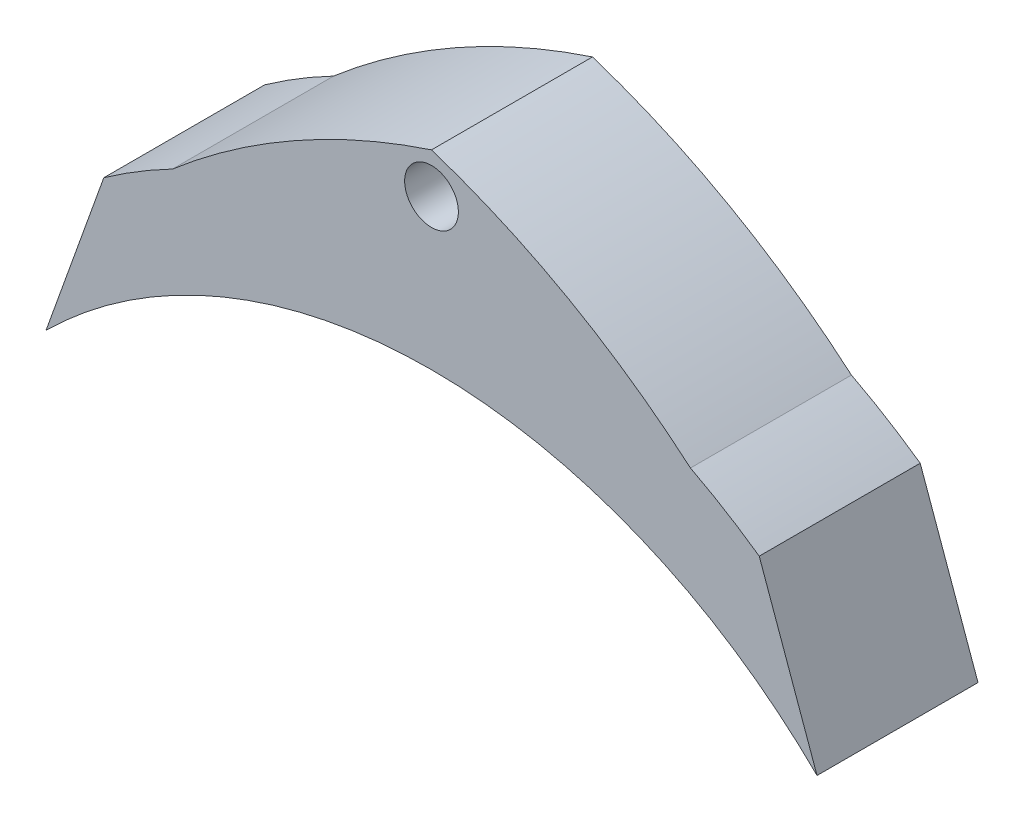
from build123d import *

# Parameters (mm, degrees)
BOSS_EXTRUDE1_DEPTH     = 30
SKETCH2_W               = 8.32
SKETCH2_H               = 8.5
SKETCH2_H_2             = 10.4
SKETCH2_W_2             = 4.158973904
SKETCH2_H_3             = 8.284744262
CUT_EXTRUDE5_DEPTH      = 8.32
CUT_EXTRUDE5_DEPTH_BACK = 8.32


with BuildPart() as part:
    # Sketch1 → Boss-Extrude1 (new body)
    with BuildSketch(Plane.XY):
        with BuildLine():
            Line((-61.072637036, 102.678177008), (-71.843049169, 72.656622079))
            ThreePointArc((-71.843049169, 72.656622079), (-38.845852098, 94.547390677), (0, 102.229873289))
            Line((0, 102.229873289), (0, 122.669843323))
            ThreePointArc((0, 122.669843323), (-24.83617604, 119.381808628), (-48.25837108, 110.490937356))
            ThreePointArc((-48.25837108, 110.490937356), (-54.800605836, 106.806147253), (-61.072637036, 102.678177008))
        make_face()
        with BuildLine():
            ThreePointArc((0, 137.710014326), (-25.468170629, 126.474444633), (-48.25837108, 110.490937356))
            ThreePointArc((-48.25837108, 110.490937356), (-24.83617604, 119.381808628), (0, 122.669843323))
            Line((0, 122.669843323), (0, 125.181241323))
            ThreePointArc((0, 125.181241323), (-5.008687502, 130.189928825), (0, 135.198616327))
            Line((0, 135.198616327), (0, 137.710014326))
        make_face()
    extrude(amount=BOSS_EXTRUDE1_DEPTH)

    # Sketch2 → Cut-Extrude5 (cut, two sides)
    with BuildSketch(Plane.XY.offset(15)) as cut_extrude5_sk:
        with Locations((-16.418701703, 104.318970145)):
            Rectangle(SKETCH2_W, SKETCH2_H)
        with Locations((-24.923280466, 103.197968007)):
            Rectangle(SKETCH2_W, SKETCH2_H_2)
        with Locations((-2.079486952, 106.272425537)):
            Rectangle(SKETCH2_W_2, SKETCH2_H_3)
    extrude(amount=CUT_EXTRUDE5_DEPTH, mode=Mode.SUBTRACT)
    extrude(cut_extrude5_sk.sketch, amount=-CUT_EXTRUDE5_DEPTH_BACK, mode=Mode.SUBTRACT)

    # Mirror3: part across plane


with BuildPart() as part_1:
    add(part.part)
    add(part.part.mirror(Plane(origin=(0, 0, 30), x_dir=(0, 0, 1), z_dir=(-1, 0, 0))))


solid = part_1.part
